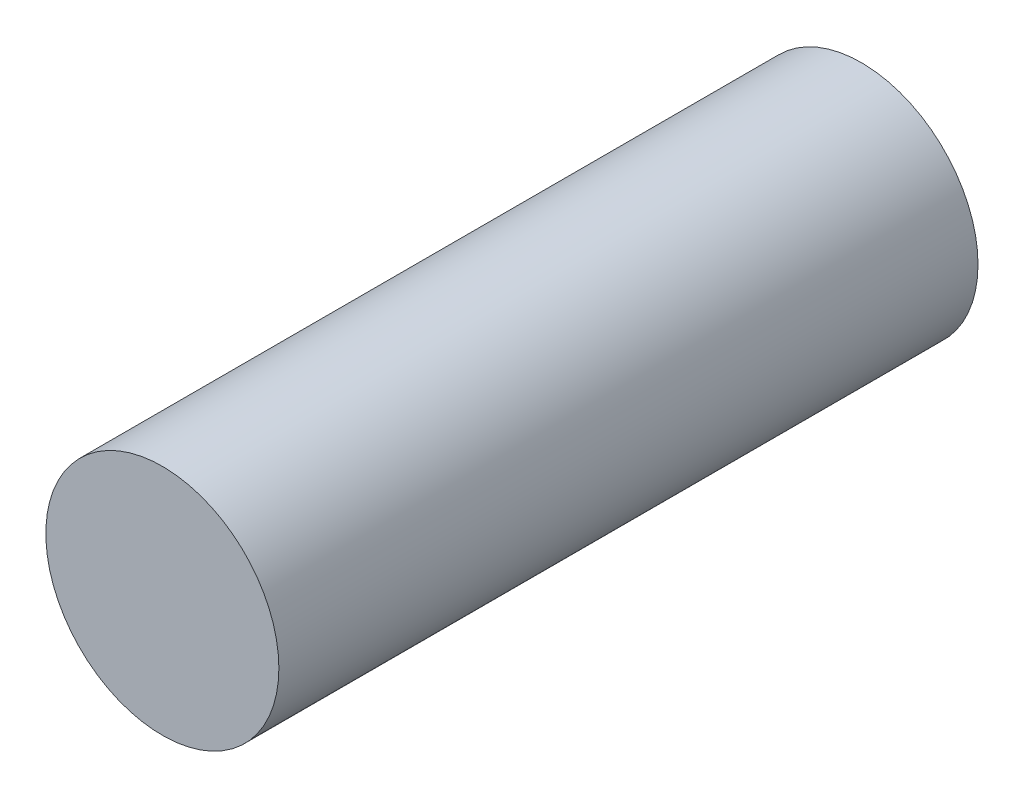
from build123d import *

# Parameters (mm, degrees)
SKETCH2_R           = 2.5
BOSS_EXTRUDE1_DEPTH = 15


with BuildPart() as part:
    # Sketch2 → Boss-Extrude1 (new body)
    with BuildSketch(Plane.XY):
        Circle(SKETCH2_R)
    extrude(amount=BOSS_EXTRUDE1_DEPTH)


solid = part.part
